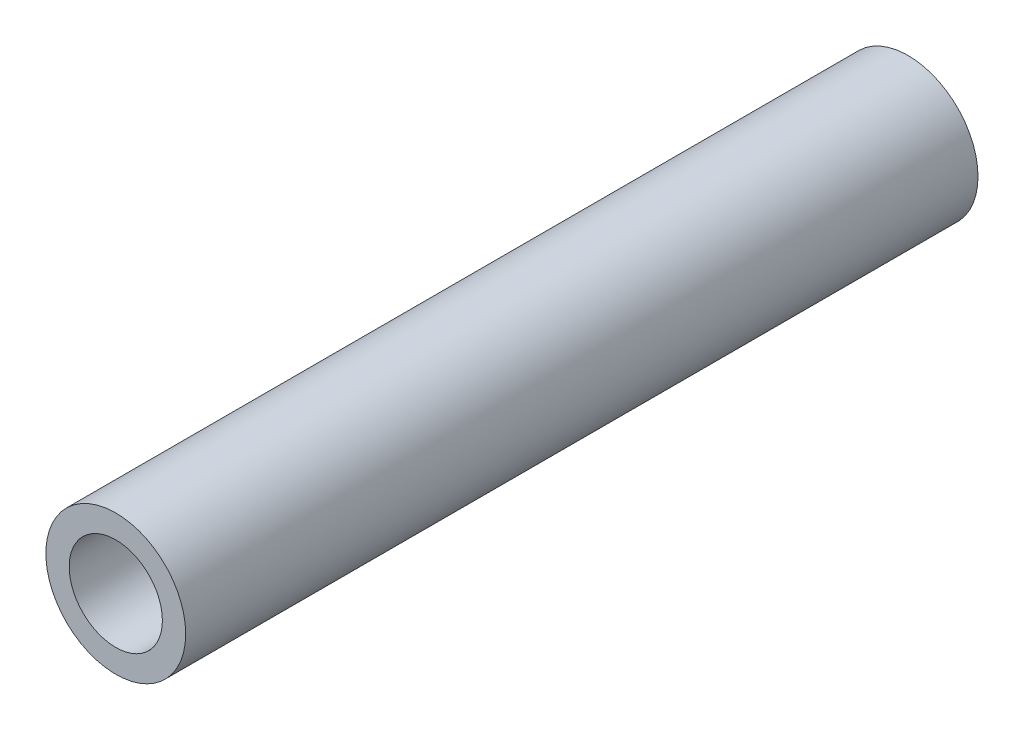
from build123d import *

# Parameters (mm, degrees)
ESQUISSE1_R        = 1.5
ESQUISSE1_R_2      = 1
BOSS_EXTRU_1_DEPTH = 17


with BuildPart() as part:
    # Esquisse1 → Boss.-Extru.1 (new body)
    with BuildSketch(Plane.XY):
        Circle(ESQUISSE1_R)
        Circle(ESQUISSE1_R_2, mode=Mode.SUBTRACT)
    extrude(amount=BOSS_EXTRU_1_DEPTH)


solid = part.part
